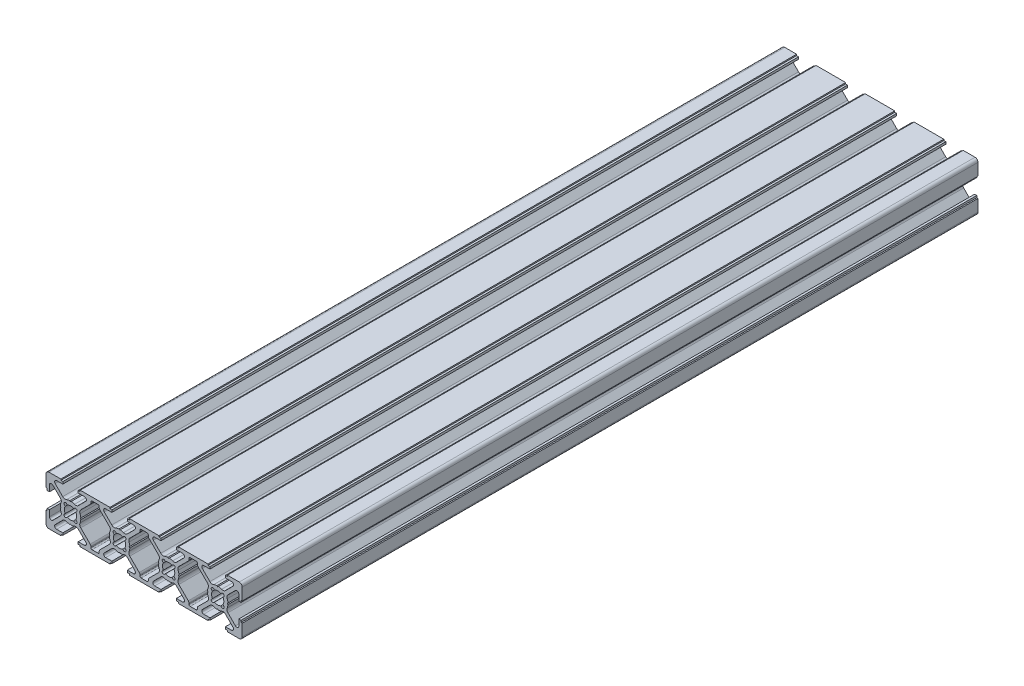
from build123d import *

# Parameters (mm, degrees)
Y_KSEKLIK_EKSTR_ZYON1_DEPTH = 300


with BuildPart() as part:
    # Model → Yükseklik-Ekstrüzyon1 (new body)
    with BuildSketch(Plane.XY):
        with BuildLine():
            Line((-8.800004195, -10.000004195), (-3.950004195, -10.000004195))
            Line((-3.950004195, -10.000004195), (-3.950004195, -9.499995805))
            Line((-3.950004195, -9.499995805), (-3.147504195, -9.499995805))
            Line((-3.147504195, -9.499995805), (-3.147504195, -8.599995805))
            Line((-3.147504195, -8.599995805), (-5.678683852, -8.599995805))
            ThreePointArc((-5.678683852, -8.599995805), (-6.417787478, -8.106142551), (-6.244369277, -7.23431038))
            Line((-6.244369277, -7.23431038), (-3.178748666, -4.168689769))
            ThreePointArc((-3.178748666, -4.168689769), (-2.455097993, -3.783144936), (-1.639430046, -3.866816407))
            ThreePointArc((-1.639430046, -3.866816407), (-0.978142037, -4.084511985), (-0.289977679, -4.189977678))
            Line((-0.289977679, -4.189977678), (0, -3.9))
            Line((0, -3.9), (0.289977678, -4.189977678))
            ThreePointArc((0.289977678, -4.189977678), (0.978142036, -4.084511985), (1.639430046, -3.866816407))
            ThreePointArc((1.639430046, -3.866816407), (2.453899272, -3.782053175), (3.17678595, -4.166734572))
            Line((3.17678595, -4.166734572), (6.244365517, -7.234314139))
            ThreePointArc((6.244365517, -7.234314139), (6.417783718, -8.10614631), (5.678680092, -8.599999564))
            Line((5.678680092, -8.599999564), (3.147500435, -8.599999564))
            Line((3.147500435, -8.599999564), (3.147500435, -9.499999564))
            Line((3.147500435, -9.499999564), (3.950000435, -9.499999564))
            Line((3.950000435, -9.499999564), (3.950000435, -10.000004195))
            Line((3.950000435, -10.000004195), (16.049995805, -10.000004195))
            Line((16.049995805, -10.000004195), (16.049995805, -9.500000435))
            Line((16.049995805, -9.500000435), (16.852495805, -9.500000435))
            Line((16.852495805, -9.500000435), (16.852495805, -8.599995805))
            Line((16.852495805, -8.599995805), (14.321316148, -8.599995805))
            ThreePointArc((14.321316148, -8.599995805), (13.582212522, -8.106142551), (13.755630723, -7.23431038))
            Line((13.755630723, -7.23431038), (16.821251334, -4.168689769))
            ThreePointArc((16.821251334, -4.168689769), (17.544902007, -3.783144936), (18.360569954, -3.866816407))
            ThreePointArc((18.360569954, -3.866816407), (19.021857963, -4.084511985), (19.710022321, -4.189977678))
            Line((19.710022321, -4.189977678), (20, -3.9))
            Line((20, -3.9), (20.289977678, -4.189977678))
            ThreePointArc((20.289977678, -4.189977678), (20.978142036, -4.084511985), (21.639430046, -3.866816407))
            ThreePointArc((21.639430046, -3.866816407), (22.453899272, -3.782053175), (23.17678595, -4.166734572))
            Line((23.17678595, -4.166734572), (26.244365517, -7.234314139))
            ThreePointArc((26.244365517, -7.234314139), (26.417783718, -8.10614631), (25.678680092, -8.599999564))
            Line((25.678680092, -8.599999564), (23.147500435, -8.599999564))
            Line((23.147500435, -8.599999564), (23.147500435, -9.499999564))
            Line((23.147500435, -9.499999564), (23.950000435, -9.499999564))
            Line((23.950000435, -9.499999564), (23.950000435, -10.000004195))
            Line((23.950000435, -10.000004195), (36.049995805, -10.000004195))
            Line((36.049995805, -10.000004195), (36.049995805, -9.500000435))
            Line((36.049995805, -9.500000435), (36.852495805, -9.500000435))
            Line((36.852495805, -9.500000435), (36.852495805, -8.599995805))
            Line((36.852495805, -8.599995805), (34.321316148, -8.599995805))
            ThreePointArc((34.321316148, -8.599995805), (33.582212522, -8.106142551), (33.755630724, -7.23431038))
            Line((33.755630724, -7.23431038), (36.821251334, -4.168689769))
            ThreePointArc((36.821251334, -4.168689769), (37.544902007, -3.783144936), (38.360569954, -3.866816407))
            ThreePointArc((38.360569954, -3.866816407), (39.021857964, -4.084511985), (39.710022322, -4.189977678))
            Line((39.710022322, -4.189977678), (40, -3.9))
            Line((40, -3.9), (40.289977679, -4.189977678))
            ThreePointArc((40.289977679, -4.189977678), (40.978142037, -4.084511985), (41.639430046, -3.866816407))
            ThreePointArc((41.639430046, -3.866816407), (42.453899273, -3.782053175), (43.17678595, -4.166734572))
            Line((43.17678595, -4.166734572), (46.244365517, -7.234314139))
            ThreePointArc((46.244365517, -7.234314139), (46.417783718, -8.10614631), (45.678680092, -8.599999564))
            Line((45.678680092, -8.599999564), (43.147500436, -8.599999564))
            Line((43.147500436, -8.599999564), (43.147500436, -9.499999564))
            Line((43.147500436, -9.499999564), (43.950000436, -9.499999564))
            Line((43.950000436, -9.499999564), (43.950000436, -10.000004195))
            Line((43.950000436, -10.000004195), (56.049995805, -10.000004195))
            Line((56.049995805, -10.000004195), (56.049995805, -9.500000435))
            Line((56.049995805, -9.500000435), (56.852495805, -9.500000435))
            Line((56.852495805, -9.500000435), (56.852495805, -8.599995805))
            Line((56.852495805, -8.599995805), (54.321316148, -8.599995805))
            ThreePointArc((54.321316148, -8.599995805), (53.582212522, -8.106142551), (53.755630723, -7.23431038))
            Line((53.755630723, -7.23431038), (56.821251334, -4.168689769))
            ThreePointArc((56.821251334, -4.168689769), (57.544902007, -3.783144936), (58.360569954, -3.866816407))
            ThreePointArc((58.360569954, -3.866816407), (59.021857963, -4.084511985), (59.710022322, -4.189977678))
            Line((59.710022322, -4.189977678), (60, -3.9))
            Line((60, -3.9), (60.289977678, -4.189977678))
            ThreePointArc((60.289977678, -4.189977678), (60.978142037, -4.084511985), (61.639430046, -3.866816407))
            ThreePointArc((61.639430046, -3.866816407), (62.453899273, -3.782053175), (63.17678595, -4.166734572))
            Line((63.17678595, -4.166734572), (66.244365517, -7.234314139))
            ThreePointArc((66.244365517, -7.234314139), (66.417783718, -8.10614631), (65.678680092, -8.599999564))
            Line((65.678680092, -8.599999564), (63.147500436, -8.599999564))
            Line((63.147500436, -8.599999564), (63.147500436, -9.499999564))
            Line((63.147500436, -9.499999564), (63.950000436, -9.499999564))
            Line((63.950000436, -9.499999564), (63.950000436, -10.000004195))
            Line((63.950000436, -10.000004195), (68.800000436, -10.000004195))
            ThreePointArc((68.800000436, -10.000004195), (69.648528573, -9.648532332), (70.000000435, -8.800004195))
            Line((70.000000435, -8.800004195), (70.000000435, -3.950004195))
            Line((70.000000435, -3.950004195), (69.499995805, -3.950004195))
            Line((69.499995805, -3.950004195), (69.499995805, -3.147739195))
            Line((69.499995805, -3.147739195), (68.599995805, -3.147739195))
            Line((68.599995805, -3.147739195), (68.599995805, -5.678683851))
            ThreePointArc((68.599995805, -5.678683851), (68.106142551, -6.417787477), (67.23431038, -6.244369276))
            Line((67.23431038, -6.244369276), (64.168689769, -3.178748666))
            ThreePointArc((64.168689769, -3.178748666), (63.783144936, -2.455097993), (63.866816407, -1.639430046))
            ThreePointArc((63.866816407, -1.639430046), (64.084511985, -0.978142036), (64.189977678, -0.289977678))
            Line((64.189977678, -0.289977678), (63.9, 0))
            Line((63.9, 0), (64.189977678, 0.289977678))
            ThreePointArc((64.189977678, 0.289977678), (64.084511985, 0.978142037), (63.866816407, 1.639430046))
            ThreePointArc((63.866816407, 1.639430046), (63.782053175, 2.453899272), (64.166734573, 3.17678595))
            Line((64.166734573, 3.17678595), (67.23431414, 6.244365517))
            ThreePointArc((67.23431414, 6.244365517), (68.106146311, 6.417783718), (68.599999565, 5.678680092))
            Line((68.599999565, 5.678680092), (68.599999565, 3.147500436))
            Line((68.599999565, 3.147500436), (69.500000436, 3.147500436))
            Line((69.500000436, 3.147500436), (69.500000436, 3.949999564))
            Line((69.500000436, 3.949999564), (70.000000435, 3.949999564))
            Line((70.000000435, 3.949999564), (70.000000435, 8.799992045))
            ThreePointArc((70.000000435, 8.799992045), (69.648529902, 9.648522613), (68.800000435, 9.999995805))
            Line((68.800000435, 9.999995805), (63.950000435, 9.999995805))
            Line((63.950000435, 9.999995805), (63.950000435, 9.499999564))
            Line((63.950000435, 9.499999564), (63.147500435, 9.499999564))
            Line((63.147500435, 9.499999564), (63.147500435, 8.599999564))
            Line((63.147500435, 8.599999564), (65.678680092, 8.599999564))
            ThreePointArc((65.678680092, 8.599999564), (66.417783718, 8.10614631), (66.244365517, 7.23431414))
            Line((66.244365517, 7.23431414), (63.17678595, 4.166734573))
            ThreePointArc((63.17678595, 4.166734573), (62.453899272, 3.782053175), (61.639430046, 3.866816407))
            ThreePointArc((61.639430046, 3.866816407), (60.978142037, 4.084511985), (60.289977678, 4.189977678))
            Line((60.289977678, 4.189977678), (60, 3.9))
            Line((60, 3.9), (59.710022322, 4.189977679))
            ThreePointArc((59.710022322, 4.189977679), (59.021857964, 4.084511985), (58.360569954, 3.866816407))
            ThreePointArc((58.360569954, 3.866816407), (57.544902007, 3.783144936), (56.821251334, 4.168689769))
            Line((56.821251334, 4.168689769), (53.755630724, 7.23431038))
            ThreePointArc((53.755630724, 7.23431038), (53.582212522, 8.106142551), (54.321316148, 8.599995805))
            Line((54.321316148, 8.599995805), (56.852500435, 8.599995805))
            Line((56.852500435, 8.599995805), (56.852500435, 9.499995805))
            Line((56.852500435, 9.499995805), (56.050000435, 9.499995805))
            Line((56.050000435, 9.499995805), (56.050000435, 9.999995805))
            Line((56.050000435, 9.999995805), (43.950000436, 9.999995805))
            Line((43.950000436, 9.999995805), (43.950000436, 9.499999564))
            Line((43.950000436, 9.499999564), (43.147500436, 9.499999564))
            Line((43.147500436, 9.499999564), (43.147500436, 8.599999564))
            Line((43.147500436, 8.599999564), (45.678680092, 8.599999564))
            ThreePointArc((45.678680092, 8.599999564), (46.417783718, 8.10614631), (46.244365517, 7.234314139))
            Line((46.244365517, 7.234314139), (43.17678595, 4.166734573))
            ThreePointArc((43.17678595, 4.166734573), (42.453899273, 3.782053175), (41.639430046, 3.866816407))
            ThreePointArc((41.639430046, 3.866816407), (40.978142037, 4.084511985), (40.289977679, 4.189977678))
            Line((40.289977679, 4.189977678), (40, 3.9))
            Line((40, 3.9), (39.710022322, 4.189977678))
            ThreePointArc((39.710022322, 4.189977678), (39.021857964, 4.084511985), (38.360569954, 3.866816407))
            ThreePointArc((38.360569954, 3.866816407), (37.544902007, 3.783144936), (36.821251334, 4.168689769))
            Line((36.821251334, 4.168689769), (33.755630724, 7.23431038))
            ThreePointArc((33.755630724, 7.23431038), (33.582212522, 8.106142551), (34.321316149, 8.599995805))
            Line((34.321316149, 8.599995805), (36.852500436, 8.599995805))
            Line((36.852500436, 8.599995805), (36.852500436, 9.499995805))
            Line((36.852500436, 9.499995805), (36.050000436, 9.499995805))
            Line((36.050000436, 9.499995805), (36.050000436, 9.999995805))
            Line((36.050000436, 9.999995805), (23.950000435, 9.999995805))
            Line((23.950000435, 9.999995805), (23.950000435, 9.499999564))
            Line((23.950000435, 9.499999564), (23.147500435, 9.499999564))
            Line((23.147500435, 9.499999564), (23.147500435, 8.599999564))
            Line((23.147500435, 8.599999564), (25.678680092, 8.599999564))
            ThreePointArc((25.678680092, 8.599999564), (26.417783718, 8.10614631), (26.244365517, 7.234314139))
            Line((26.244365517, 7.234314139), (23.17678595, 4.166734573))
            ThreePointArc((23.17678595, 4.166734573), (22.453899272, 3.782053175), (21.639430046, 3.866816407))
            ThreePointArc((21.639430046, 3.866816407), (20.978142036, 4.084511985), (20.289977678, 4.189977678))
            Line((20.289977678, 4.189977678), (20, 3.9))
            Line((20, 3.9), (19.710022321, 4.189977678))
            ThreePointArc((19.710022321, 4.189977678), (19.021857963, 4.084511985), (18.360569954, 3.866816407))
            ThreePointArc((18.360569954, 3.866816407), (17.544902007, 3.783144936), (16.821251334, 4.168689769))
            Line((16.821251334, 4.168689769), (13.755630723, 7.23431038))
            ThreePointArc((13.755630723, 7.23431038), (13.582212522, 8.106142551), (14.321316148, 8.599995805))
            Line((14.321316148, 8.599995805), (16.852500435, 8.599995805))
            Line((16.852500435, 8.599995805), (16.852500435, 9.499995805))
            Line((16.852500435, 9.499995805), (16.050000435, 9.499995805))
            Line((16.050000435, 9.499995805), (16.050000435, 9.999995805))
            Line((16.050000435, 9.999995805), (3.950000435, 9.999995805))
            Line((3.950000435, 9.999995805), (3.950000435, 9.499999565))
            Line((3.950000435, 9.499999565), (3.147500435, 9.499999565))
            Line((3.147500435, 9.499999565), (3.147500435, 8.599999565))
            Line((3.147500435, 8.599999565), (5.678680092, 8.599999565))
            ThreePointArc((5.678680092, 8.599999565), (6.417783718, 8.10614631), (6.244365517, 7.23431414))
            Line((6.244365517, 7.23431414), (3.17678595, 4.166734573))
            ThreePointArc((3.17678595, 4.166734573), (2.453899272, 3.782053175), (1.639430046, 3.866816407))
            ThreePointArc((1.639430046, 3.866816407), (0.978142036, 4.084511985), (0.289977678, 4.189977679))
            Line((0.289977678, 4.189977679), (0, 3.9))
            Line((0, 3.9), (-0.289977679, 4.189977678))
            ThreePointArc((-0.289977679, 4.189977678), (-0.978142037, 4.084511985), (-1.639430046, 3.866816407))
            ThreePointArc((-1.639430046, 3.866816407), (-2.455097993, 3.783144936), (-3.178748666, 4.168689769))
            Line((-3.178748666, 4.168689769), (-6.244369277, 7.23431038))
            ThreePointArc((-6.244369277, 7.23431038), (-6.417787478, 8.106142551), (-5.678683852, 8.599995805))
            Line((-5.678683852, 8.599995805), (-3.147504195, 8.599995805))
            Line((-3.147504195, 8.599995805), (-3.147504195, 9.499995805))
            Line((-3.147504195, 9.499995805), (-3.950004195, 9.499995805))
            Line((-3.950004195, 9.499995805), (-3.950004195, 9.999995805))
            Line((-3.950004195, 9.999995805), (-8.800004195, 9.999995805))
            ThreePointArc((-8.800004195, 9.999995805), (-9.648532333, 9.648523942), (-10.000004195, 8.799995805))
            Line((-10.000004195, 8.799995805), (-10.000004195, 3.949995805))
            Line((-10.000004195, 3.949995805), (-9.500004195, 3.949995805))
            Line((-9.500004195, 3.949995805), (-9.500004195, 3.147495805))
            Line((-9.500004195, 3.147495805), (-8.599999564, 3.147495805))
            Line((-8.599999564, 3.147495805), (-8.599999564, 5.678680092))
            ThreePointArc((-8.599999564, 5.678680092), (-8.10614631, 6.417783718), (-7.234314139, 6.244365517))
            Line((-7.234314139, 6.244365517), (-4.166734573, 3.17678595))
            ThreePointArc((-4.166734573, 3.17678595), (-3.782053175, 2.453899272), (-3.866816407, 1.639430046))
            ThreePointArc((-3.866816407, 1.639430046), (-4.084511985, 0.978142037), (-4.189977678, 0.289977678))
            Line((-4.189977678, 0.289977678), (-3.9, 0))
            Line((-3.9, 0), (-4.189977678, -0.289977678))
            ThreePointArc((-4.189977678, -0.289977678), (-4.084511985, -0.978142036), (-3.866816407, -1.639430046))
            ThreePointArc((-3.866816407, -1.639430046), (-3.783144936, -2.455097993), (-4.168689769, -3.178748666))
            Line((-4.168689769, -3.178748666), (-7.23431038, -6.244369276))
            ThreePointArc((-7.23431038, -6.244369276), (-8.106142551, -6.417787477), (-8.599995805, -5.678683851))
            Line((-8.599995805, -5.678683851), (-8.599995805, -3.147504195))
            Line((-8.599995805, -3.147504195), (-9.499995805, -3.147504195))
            Line((-9.499995805, -3.147504195), (-9.499995805, -3.950004195))
            Line((-9.499995805, -3.950004195), (-10.000004195, -3.950004195))
            Line((-10.000004195, -3.950004195), (-10.000004195, -8.800004195))
            ThreePointArc((-10.000004195, -8.800004195), (-9.648532333, -9.648532332), (-8.800004195, -10.000004195))
        make_face()
        with BuildLine():
            Line((62.140364299, 1.291836162), (62.474873734, 1.626345597))
            ThreePointArc((62.474873734, 1.626345597), (62.474873734, 2.474873734), (61.626345597, 2.474873734))
            Line((61.626345597, 2.474873734), (61.291836161, 2.140364299))
            ThreePointArc((61.291836161, 2.140364299), (60, 2.5), (58.708163839, 2.140364299))
            Line((58.708163839, 2.140364299), (58.373654403, 2.474873734))
            ThreePointArc((58.373654403, 2.474873734), (57.525126266, 2.474873734), (57.525126266, 1.626345597))
            Line((57.525126266, 1.626345597), (57.859635701, 1.291836162))
            ThreePointArc((57.859635701, 1.291836162), (57.5, 0), (57.859635701, -1.291836161))
            Line((57.859635701, -1.291836161), (57.525126266, -1.626345597))
            ThreePointArc((57.525126266, -1.626345597), (57.525126266, -2.474873734), (58.373654403, -2.474873734))
            Line((58.373654403, -2.474873734), (58.708163839, -2.140364299))
            ThreePointArc((58.708163839, -2.140364299), (60, -2.5), (61.291836162, -2.140364299))
            Line((61.291836162, -2.140364299), (61.626345597, -2.474873734))
            ThreePointArc((61.626345597, -2.474873734), (62.474873734, -2.474873734), (62.474873734, -1.626345597))
            Line((62.474873734, -1.626345597), (62.140364299, -1.291836161))
            ThreePointArc((62.140364299, -1.291836161), (62.5, 0), (62.140364299, 1.291836162))
        make_face(mode=Mode.SUBTRACT)
        with BuildLine():
            Line((55.834194285, -3.175856222), (51.989949494, -7.020101012))
            ThreePointArc((51.989949494, -7.020101012), (51.773176743, -7.344524361), (51.697056275, -7.727207794))
            Line((51.697056275, -7.727207794), (51.697056275, -8.1))
            ThreePointArc((51.697056275, -8.1), (51.550609666, -8.453553391), (51.197056275, -8.6))
            Line((51.197056275, -8.6), (48.802943725, -8.6))
            ThreePointArc((48.802943725, -8.6), (48.449390335, -8.453553391), (48.302943725, -8.1))
            Line((48.302943725, -8.1), (48.302943725, -7.727207794))
            ThreePointArc((48.302943725, -7.727207794), (48.226823258, -7.344524362), (48.010050506, -7.020101013))
            Line((48.010050506, -7.020101013), (44.165805715, -3.175856222))
            ThreePointArc((44.165805715, -3.175856222), (43.781533861, -2.453330896), (43.866816407, -1.639430046))
            ThreePointArc((43.866816407, -1.639430046), (44.084511985, -0.978142037), (44.189977678, -0.289977678))
            Line((44.189977678, -0.289977678), (43.9, 0))
            Line((43.9, 0), (44.189977678, 0.289977678))
            ThreePointArc((44.189977678, 0.289977678), (44.084511985, 0.978142037), (43.866816407, 1.639430046))
            ThreePointArc((43.866816407, 1.639430046), (43.781533861, 2.453330896), (44.165805715, 3.175856222))
            Line((44.165805715, 3.175856222), (48.010050506, 7.020101013))
            ThreePointArc((48.010050506, 7.020101013), (48.226823258, 7.344524362), (48.302943725, 7.727207794))
            Line((48.302943725, 7.727207794), (48.302943725, 8.1))
            ThreePointArc((48.302943725, 8.1), (48.449390335, 8.453553391), (48.802943725, 8.6))
            Line((48.802943725, 8.6), (51.197056275, 8.6))
            ThreePointArc((51.197056275, 8.6), (51.550609665, 8.453553391), (51.697056275, 8.1))
            Line((51.697056275, 8.1), (51.697056275, 7.727207794))
            ThreePointArc((51.697056275, 7.727207794), (51.773176742, 7.344524361), (51.989949494, 7.020101013))
            Line((51.989949494, 7.020101013), (55.834194285, 3.175856222))
            ThreePointArc((55.834194285, 3.175856222), (56.218466139, 2.453330896), (56.133183593, 1.639430046))
            ThreePointArc((56.133183593, 1.639430046), (55.915488015, 0.978142037), (55.810022322, 0.289977678))
            Line((55.810022322, 0.289977678), (56.1, 0))
            Line((56.1, 0), (55.810022322, -0.289977678))
            ThreePointArc((55.810022322, -0.289977678), (55.915488015, -0.978142037), (56.133183593, -1.639430046))
            ThreePointArc((56.133183593, -1.639430046), (56.218466139, -2.453330896), (55.834194285, -3.175856222))
        make_face(mode=Mode.SUBTRACT)
        with BuildLine():
            Line((-2.140364299, 1.291836161), (-2.474873734, 1.626345597))
            ThreePointArc((-2.474873734, 1.626345597), (-2.474873734, 2.474873734), (-1.626345597, 2.474873734))
            Line((-1.626345597, 2.474873734), (-1.291836161, 2.140364299))
            ThreePointArc((-1.291836161, 2.140364299), (0, 2.5), (1.291836161, 2.140364299))
            Line((1.291836161, 2.140364299), (1.626345596, 2.474873734))
            ThreePointArc((1.626345596, 2.474873734), (2.474873734, 2.474873734), (2.474873734, 1.626345597))
            Line((2.474873734, 1.626345597), (2.140364299, 1.291836162))
            ThreePointArc((2.140364299, 1.291836162), (2.5, 0), (2.140364299, -1.291836161))
            Line((2.140364299, -1.291836161), (2.474873734, -1.626345597))
            ThreePointArc((2.474873734, -1.626345597), (2.474873734, -2.474873734), (1.626345597, -2.474873734))
            Line((1.626345597, -2.474873734), (1.291836161, -2.140364299))
            ThreePointArc((1.291836161, -2.140364299), (0, -2.5), (-1.291836162, -2.140364299))
            Line((-1.291836162, -2.140364299), (-1.626345597, -2.474873734))
            ThreePointArc((-1.626345597, -2.474873734), (-2.474873734, -2.474873734), (-2.474873734, -1.626345597))
            Line((-2.474873734, -1.626345597), (-2.140364299, -1.291836161))
            ThreePointArc((-2.140364299, -1.291836161), (-2.5, 0), (-2.140364299, 1.291836161))
        make_face(mode=Mode.SUBTRACT)
        with BuildLine():
            Line((4.165805715, -3.175856222), (8.010050506, -7.020101012))
            ThreePointArc((8.010050506, -7.020101012), (8.226823257, -7.344524361), (8.302943725, -7.727207794))
            Line((8.302943725, -7.727207794), (8.302943725, -8.1))
            ThreePointArc((8.302943725, -8.1), (8.449390334, -8.45355339), (8.802943725, -8.6))
            Line((8.802943725, -8.6), (11.197056275, -8.6))
            ThreePointArc((11.197056275, -8.6), (11.550609665, -8.453553391), (11.697056275, -8.1))
            Line((11.697056275, -8.1), (11.697056275, -7.727207794))
            ThreePointArc((11.697056275, -7.727207794), (11.773176742, -7.344524362), (11.989949494, -7.020101013))
            Line((11.989949494, -7.020101013), (15.834194285, -3.175856222))
            ThreePointArc((15.834194285, -3.175856222), (16.218466139, -2.453330896), (16.133183593, -1.639430046))
            ThreePointArc((16.133183593, -1.639430046), (15.915488015, -0.978142037), (15.810022322, -0.289977678))
            Line((15.810022322, -0.289977678), (16.1, 0))
            Line((16.1, 0), (15.810022321, 0.289977678))
            ThreePointArc((15.810022321, 0.289977678), (15.915488015, 0.978142037), (16.133183593, 1.639430046))
            ThreePointArc((16.133183593, 1.639430046), (16.218466139, 2.453330896), (15.834194284, 3.175856222))
            Line((15.834194284, 3.175856222), (11.989949494, 7.020101013))
            ThreePointArc((11.989949494, 7.020101013), (11.773176742, 7.344524362), (11.697056275, 7.727207794))
            Line((11.697056275, 7.727207794), (11.697056275, 8.1))
            ThreePointArc((11.697056275, 8.1), (11.550609665, 8.453553391), (11.197056275, 8.6))
            Line((11.197056275, 8.6), (8.802943725, 8.6))
            ThreePointArc((8.802943725, 8.6), (8.449390334, 8.453553391), (8.302943725, 8.1))
            Line((8.302943725, 8.1), (8.302943725, 7.727207794))
            ThreePointArc((8.302943725, 7.727207794), (8.226823258, 7.344524362), (8.010050506, 7.020101013))
            Line((8.010050506, 7.020101013), (4.165805715, 3.175856222))
            ThreePointArc((4.165805715, 3.175856222), (3.78153386, 2.453330896), (3.866816407, 1.639430046))
            ThreePointArc((3.866816407, 1.639430046), (4.084511985, 0.978142037), (4.189977678, 0.289977678))
            Line((4.189977678, 0.289977678), (3.9, 0))
            Line((3.9, 0), (4.189977678, -0.289977678))
            ThreePointArc((4.189977678, -0.289977678), (4.084511985, -0.978142037), (3.866816407, -1.639430046))
            ThreePointArc((3.866816407, -1.639430046), (3.781533861, -2.453330896), (4.165805715, -3.175856222))
        make_face(mode=Mode.SUBTRACT)
        with BuildLine():
            Line((17.859635701, 1.291836161), (17.525126266, 1.626345597))
            ThreePointArc((17.525126266, 1.626345597), (17.525126266, 2.474873734), (18.373654403, 2.474873734))
            Line((18.373654403, 2.474873734), (18.708163838, 2.140364299))
            ThreePointArc((18.708163838, 2.140364299), (20, 2.5), (21.291836161, 2.140364299))
            Line((21.291836161, 2.140364299), (21.626345597, 2.474873734))
            ThreePointArc((21.626345597, 2.474873734), (22.474873734, 2.474873734), (22.474873734, 1.626345597))
            Line((22.474873734, 1.626345597), (22.140364299, 1.291836161))
            ThreePointArc((22.140364299, 1.291836161), (22.5, 0), (22.140364299, -1.291836161))
            Line((22.140364299, -1.291836161), (22.474873734, -1.626345597))
            ThreePointArc((22.474873734, -1.626345597), (22.474873734, -2.474873734), (21.626345597, -2.474873734))
            Line((21.626345597, -2.474873734), (21.291836161, -2.140364299))
            ThreePointArc((21.291836161, -2.140364299), (20, -2.5), (18.708163838, -2.140364299))
            Line((18.708163838, -2.140364299), (18.373654403, -2.474873734))
            ThreePointArc((18.373654403, -2.474873734), (17.525126266, -2.474873734), (17.525126266, -1.626345597))
            Line((17.525126266, -1.626345597), (17.859635701, -1.291836161))
            ThreePointArc((17.859635701, -1.291836161), (17.5, 0), (17.859635701, 1.291836161))
        make_face(mode=Mode.SUBTRACT)
        with BuildLine():
            Line((37.859635701, 1.291836161), (37.525126266, 1.626345597))
            ThreePointArc((37.525126266, 1.626345597), (37.525126266, 2.474873734), (38.373654403, 2.474873734))
            Line((38.373654403, 2.474873734), (38.708163839, 2.140364299))
            ThreePointArc((38.708163839, 2.140364299), (40, 2.5), (41.291836162, 2.140364299))
            Line((41.291836162, 2.140364299), (41.626345597, 2.474873734))
            ThreePointArc((41.626345597, 2.474873734), (42.474873734, 2.474873734), (42.474873734, 1.626345597))
            Line((42.474873734, 1.626345597), (42.140364299, 1.291836161))
            ThreePointArc((42.140364299, 1.291836161), (42.5, 0), (42.140364299, -1.291836161))
            Line((42.140364299, -1.291836161), (42.474873734, -1.626345597))
            ThreePointArc((42.474873734, -1.626345597), (42.474873734, -2.474873734), (41.626345597, -2.474873734))
            Line((41.626345597, -2.474873734), (41.291836162, -2.140364299))
            ThreePointArc((41.291836162, -2.140364299), (40, -2.5), (38.708163839, -2.140364299))
            Line((38.708163839, -2.140364299), (38.373654403, -2.474873734))
            ThreePointArc((38.373654403, -2.474873734), (37.525126266, -2.474873734), (37.525126266, -1.626345597))
            Line((37.525126266, -1.626345597), (37.859635701, -1.291836161))
            ThreePointArc((37.859635701, -1.291836161), (37.5, 0), (37.859635701, 1.291836161))
        make_face(mode=Mode.SUBTRACT)
        with BuildLine():
            Line((24.165805716, -3.175856222), (28.010050507, -7.020101013))
            ThreePointArc((28.010050507, -7.020101013), (28.226823258, -7.344524362), (28.302943726, -7.727207794))
            Line((28.302943726, -7.727207794), (28.302943726, -8.1))
            ThreePointArc((28.302943726, -8.1), (28.449390335, -8.453553391), (28.802943726, -8.6))
            Line((28.802943726, -8.6), (31.197056275, -8.6))
            ThreePointArc((31.197056275, -8.6), (31.550609666, -8.453553391), (31.697056275, -8.1))
            Line((31.697056275, -8.1), (31.697056275, -7.727207794))
            ThreePointArc((31.697056275, -7.727207794), (31.773176743, -7.344524362), (31.989949494, -7.020101013))
            Line((31.989949494, -7.020101013), (35.834194285, -3.175856222))
            ThreePointArc((35.834194285, -3.175856222), (36.21846614, -2.453330896), (36.133183594, -1.639430046))
            ThreePointArc((36.133183594, -1.639430046), (35.915488015, -0.978142037), (35.810022322, -0.289977678))
            Line((35.810022322, -0.289977678), (36.1, 0))
            Line((36.1, 0), (35.810022322, 0.289977678))
            ThreePointArc((35.810022322, 0.289977678), (35.915488015, 0.978142037), (36.133183594, 1.639430046))
            ThreePointArc((36.133183594, 1.639430046), (36.21846614, 2.453330896), (35.834194285, 3.175856222))
            Line((35.834194285, 3.175856222), (31.989949494, 7.020101013))
            ThreePointArc((31.989949494, 7.020101013), (31.773176743, 7.344524362), (31.697056275, 7.727207794))
            Line((31.697056275, 7.727207794), (31.697056275, 8.1))
            ThreePointArc((31.697056275, 8.1), (31.550609666, 8.453553391), (31.197056275, 8.6))
            Line((31.197056275, 8.6), (28.802943725, 8.6))
            ThreePointArc((28.802943725, 8.6), (28.449390335, 8.453553391), (28.302943725, 8.1))
            Line((28.302943725, 8.1), (28.302943725, 7.727207794))
            ThreePointArc((28.302943725, 7.727207794), (28.226823258, 7.344524361), (28.010050507, 7.020101013))
            Line((28.010050507, 7.020101013), (24.165805716, 3.175856222))
            ThreePointArc((24.165805716, 3.175856222), (23.781533861, 2.453330896), (23.866816407, 1.639430046))
            ThreePointArc((23.866816407, 1.639430046), (24.084511985, 0.978142037), (24.189977679, 0.289977678))
            Line((24.189977679, 0.289977678), (23.9, 0))
            Line((23.9, 0), (24.189977679, -0.289977678))
            ThreePointArc((24.189977679, -0.289977678), (24.084511985, -0.978142037), (23.866816407, -1.639430046))
            ThreePointArc((23.866816407, -1.639430046), (23.781533861, -2.453330896), (24.165805716, -3.175856222))
        make_face(mode=Mode.SUBTRACT)
    extrude(amount=-Y_KSEKLIK_EKSTR_ZYON1_DEPTH)


solid = part.part
